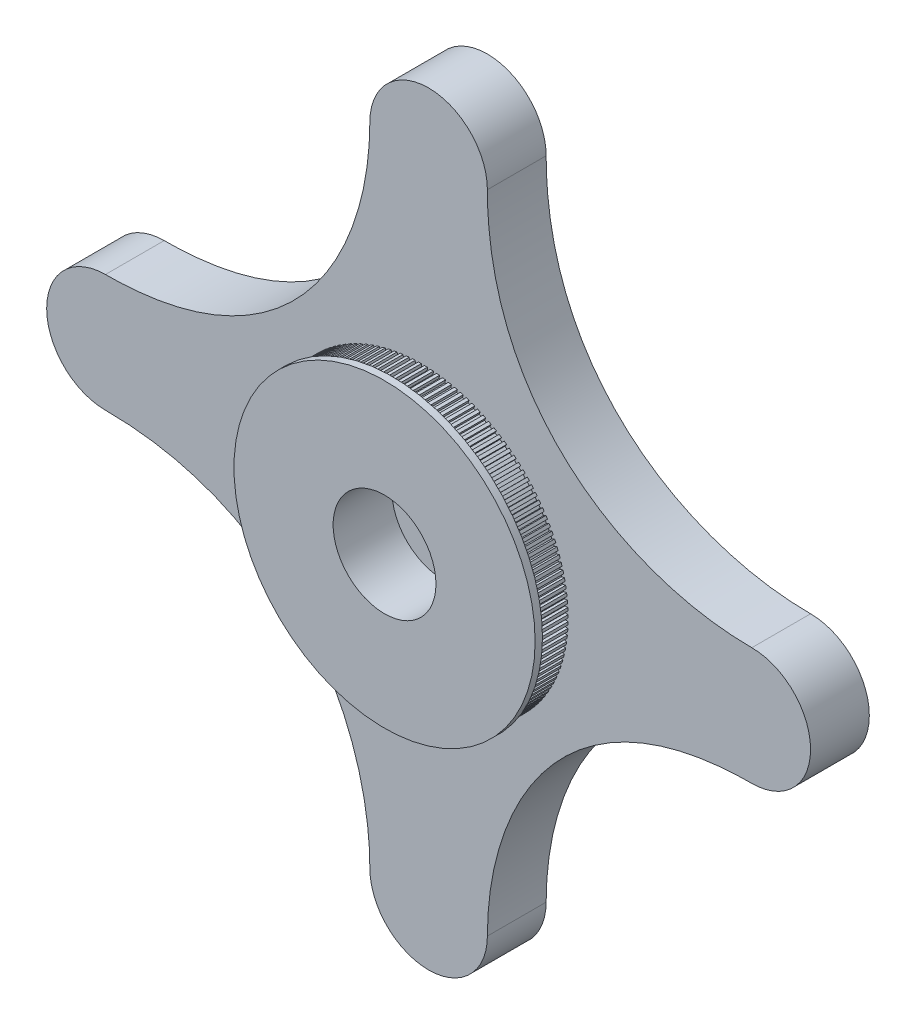
from build123d import *

# Parameters (mm, degrees)
BOSS_EXTRUDE4_DEPTH = 20
SKETCH5_R           = 7.5
BOSS_EXTRUDE5_DEPTH = 2.5
SKETCH6_R           = 45
BOSS_EXTRUDE7_DEPTH = 2.5
SKETCH7_R           = 50
BOSS_EXTRUDE8_DEPTH = 10
SKETCH11_R          = 58.029840761
CUT_EXTRUDE3_DEPTH  = 10
SKETCH9_R           = 51.25
BOSS_EXTRUDE9_DEPTH = 2.5
SKETCH10_R          = 17.5
CUT_EXTRUDE2_DEPTH  = 20


with BuildPart() as part:
    # Sketch1 → Boss-Extrude4 (new body)
    with BuildSketch(Plane.XY):
        with BuildLine():
            ThreePointArc((-20, -110), (0, -130), (20, -110))
            add(Edge.make_bspline(
                [(110, -20), (47.479354006, -20), (20, -67.573593129), (20, -110)],
                knots=[0, 0, 0, 0, 1, 1, 1, 1], degree=3))
            ThreePointArc((110, -20), (130, 0), (110, 20))
            add(Edge.make_bspline(
                [(110, 20), (67.573593129, 20), (20, 47.479354006), (20, 110)],
                knots=[0, 0, 0, 0, 1, 1, 1, 1], degree=3))
            ThreePointArc((20, 110), (0, 130), (-20, 110))
            add(Edge.make_bspline(
                [(-20, 110), (-20, 67.573593129), (-47.479354006, 20), (-110, 20)],
                knots=[0, 0, 0, 0, 1, 1, 1, 1], degree=3))
            ThreePointArc((-110, 20), (-130, 0), (-110, -20))
            add(Edge.make_bspline(
                [(-110, -20), (-47.479354006, -20), (-20, -67.573593129), (-20, -110)],
                knots=[0, 0, 0, 0, 1, 1, 1, 1], degree=3))
        make_face()
    extrude(amount=BOSS_EXTRUDE4_DEPTH)

    # Sketch5 → Boss-Extrude5 (add)
    with BuildSketch(Plane(origin=(0, 0, 0), x_dir=(-1, 0, 0), z_dir=(0, 0, -1))):
        with Locations((0, 110)):
            Circle(SKETCH5_R)
        with Locations((-110, 0)):
            Circle(SKETCH5_R)
        with Locations((0, -110)):
            Circle(SKETCH5_R)
        with Locations((110, 0)):
            Circle(SKETCH5_R)
    extrude(amount=BOSS_EXTRUDE5_DEPTH)

    # Sketch6 → Boss-Extrude7 (add)
    with BuildSketch(Plane.XY.offset(20)):
        Circle(SKETCH6_R)
    extrude(amount=BOSS_EXTRUDE7_DEPTH)

    # Sketch7 → Boss-Extrude8 (add)
    with BuildSketch(Plane.XY.offset(22.5)):
        Circle(SKETCH7_R)
    extrude(amount=BOSS_EXTRUDE8_DEPTH)

    # Sketch11 → Cut-Extrude3 (cut)
    with BuildSketch(Plane.XY.offset(32.5)):
        Circle(SKETCH11_R)
        Polygon((0, -49), (0, -49.994133884), (1, -49.98413171), (1, -48.989794856), (2.024923738, -48.958142161), (2.066006295, -49.951426814), (3.064738714, -49.90010821), (3.023647769, -48.90662076), (4.046387928, -48.832640157), (4.128482854, -49.82337857), (5.124241374, -49.730831213), (5.042129687, -48.739890523), (6.060938932, -48.623708407), (6.183905968, -49.610207919), (7.174989353, -49.476589925), (7.051997211, -48.489889001), (8.065134924, -48.331703867), (8.228763983, -49.31227906), (9.213478983, -49.137818712), (9.049816516, -48.157043317), (10.055551768, -47.957125421), (10.259563293, -48.930101), (11.236227539, -48.715096361), (11.032174361, -47.741922132), (12.02878887, -47.500613031), (12.272834311, -48.464326682), (13.239779188, -48.209145085), (12.995683921, -47.245234674), (13.981474988, -46.96294664), (14.265137397, -47.915751876), (15.220710897, -47.620829293), (14.936990573, -46.667829525), (15.910273991, -46.345044843), (16.233068735, -47.285313811), (17.175638277, -46.951154113), (16.852777628, -46.010693173), (17.811890558, -45.647963315), (18.173266148, -46.574089581), (19.101221366, -46.201263674), (18.739771994, -45.274948322), (19.683075808, -44.872893006), (20.082414841, -45.7832943), (20.99417034, -45.372439151), (20.594749775, -44.461851982), (21.520632854, -44.021158113), (21.957253064, -44.914279029), (22.851251125, -44.466096577), (22.414541771, -43.572793314), (23.321422259, -43.094213809), (23.794577689, -43.968528465), (24.669290932, -43.483784423), (24.196038898, -42.60929126), (25.082367405, -42.093643764), (25.591249677, -42.947658408), (26.445183668, -42.427180952), (25.936197499, -41.572991945), (26.800459748, -41.021157435), (27.344199445, -41.853412997), (28.175895252, -41.298091354), (27.632044541, -40.465665872), (28.472763955, -39.878587146), (29.050432106, -40.687661732), (29.858468792, -40.09844466), (29.280682699, -39.289204887), (30.096422922, -38.66788496), (30.707032591, -39.45239628), (31.490029638, -38.830290447), (30.879295302, -38.045618955), (31.668662655, -37.391119342), (32.311170627, -38.14972707), (33.067790297, -37.495795333), (32.425151146, -36.737032721), (33.18679701, -36.050471623), (33.860105569, -36.781879692), (34.589055191, -36.097239281), (33.915609164, -35.365681883), (34.648232278, -34.648232278), (35.351191089, -35.351191089), (36.051225265, -34.637011703), (35.348122933, -33.93390937), (36.050471623, -33.18679701), (36.781879692, -33.860105569), (37.451802425, -33.11760737), (36.720245026, -32.444161343), (37.391119342, -31.668662655), (38.14972707, -32.311170627), (38.788393808, -31.541622161), (38.029631197, -30.89898301), (38.66788496, -30.096422922), (39.45239628, -30.707032591), (40.058715872, -29.91174862), (39.27404438, -29.301014283), (39.878587146, -28.472763955), (40.687661732, -29.050432106), (41.260598291, -28.230771357), (40.451358518, -27.652985265), (41.021157435, -26.800459748), (41.853412997, -27.344199445), (42.391987671, -26.501562296), (41.559562188, -25.957711585), (42.093643764, -25.082367405), (42.947658408, -25.591249677), (43.45095105, -24.72707576), (42.596762044, -24.21808959), (43.094213809, -23.321422259), (43.968528465, -23.794577689), (44.435679209, -22.910343429), (43.561186046, -22.437091396), (44.021158113, -21.520632854), (44.914279029, -21.957253064), (45.344489755, -21.054469162), (44.451186492, -20.617759807), (44.872893006, -19.683075808), (45.7832943, -20.082414841), (46.17583, -19.162623686), (45.265242832, -18.763203122), (45.647963315, -17.811890558), (46.574089581, -18.173266148), (46.928279615, -17.23803919), (46.001964264, -16.876589818), (46.345044843, -15.910273991), (47.285313811, -16.233068735), (47.600553052, -15.284003793), (46.660092111, -14.961143144), (46.96294664, -13.981474988), (47.915751876, -14.265137397), (48.191501742, -13.303855932), (47.238501974, -13.020135608), (47.500613031, -12.02878887), (48.464326682, -12.272834311), (48.700116059, -11.300978656), (47.736205649, -11.056883389), (47.957125421, -10.055551768), (48.930101, -10.259563293), (49.125527046, -9.278793848), (48.152352817, -9.07474067), (48.331703867, -8.065134924), (49.31227906, -8.228763983), (49.467007893, -7.240756376), (48.486232498, -7.077093909), (48.623708407, -6.060938932), (49.610207919, -6.183905968), (49.723975187, -5.190348193), (48.737274264, -5.067356051), (48.832640157, -4.046387928), (49.82337857, -4.128482854), (49.895989904, -3.131072388), (48.905049214, -3.048960701), (48.958142161, -2.024923738), (49.951426814, -2.066006295), (49.982758159, -1.066447197), (48.989270709, -1.025356252), (49, 0), (49.994133884, 0), (49.98413171, 1), (48.989794856, 1), (48.958142161, 2.024923738), (49.951426814, 2.066006295), (49.90010821, 3.064738714), (48.90662076, 3.023647769), (48.832640157, 4.046387928), (49.82337857, 4.128482854), (49.730831213, 5.124241374), (48.739890523, 5.042129687), (48.623708407, 6.060938932), (49.610207919, 6.183905968), (49.476589925, 7.174989353), (48.489889001, 7.051997211), (48.331703867, 8.065134924), (49.31227906, 8.228763983), (49.137818712, 9.213478983), (48.157043317, 9.049816516), (47.957125421, 10.055551768), (48.930101, 10.259563293), (48.715096361, 11.236227539), (47.741922132, 11.032174361), (47.500613031, 12.02878887), (48.464326682, 12.272834311), (48.209145085, 13.239779188), (47.245234674, 12.995683921), (46.96294664, 13.981474988), (47.915751876, 14.265137397), (47.620829293, 15.220710897), (46.667829525, 14.936990573), (46.345044843, 15.910273991), (47.285313811, 16.233068735), (46.951154113, 17.175638277), (46.010693173, 16.852777628), (45.647963315, 17.811890558), (46.574089581, 18.173266148), (46.201263674, 19.101221366), (45.274948322, 18.739771994), (44.872893006, 19.683075808), (45.7832943, 20.082414841), (45.372439151, 20.99417034), (44.461851982, 20.594749775), (44.021158113, 21.520632854), (44.914279029, 21.957253064), (44.466096577, 22.851251125), (43.572793314, 22.414541771), (43.094213809, 23.321422259), (43.968528465, 23.794577689), (43.483784423, 24.669290932), (42.60929126, 24.196038898), (42.093643764, 25.082367405), (42.947658408, 25.591249677), (42.427180952, 26.445183668), (41.572991945, 25.936197499), (41.021157435, 26.800459748), (41.853412997, 27.344199445), (41.298091354, 28.175895252), (40.465665872, 27.632044541), (39.878587146, 28.472763955), (40.687661732, 29.050432106), (40.09844466, 29.858468792), (39.289204887, 29.280682699), (38.66788496, 30.096422922), (39.45239628, 30.707032591), (38.830290447, 31.490029638), (38.045618955, 30.879295302), (37.391119342, 31.668662655), (38.14972707, 32.311170627), (37.495795333, 33.067790297), (36.737032721, 32.425151146), (36.050471623, 33.18679701), (36.781879692, 33.860105569), (36.097239281, 34.589055191), (35.365681883, 33.915609164), (34.648232278, 34.648232278), (35.351191089, 35.351191089), (34.637011703, 36.051225265), (33.93390937, 35.348122933), (33.18679701, 36.050471623), (33.860105569, 36.781879692), (33.11760737, 37.451802425), (32.444161343, 36.720245026), (31.668662655, 37.391119342), (32.311170627, 38.14972707), (31.541622161, 38.788393808), (30.89898301, 38.029631197), (30.096422922, 38.66788496), (30.707032591, 39.45239628), (29.91174862, 40.058715872), (29.301014283, 39.27404438), (28.472763955, 39.878587146), (29.050432106, 40.687661732), (28.230771357, 41.260598291), (27.652985265, 40.451358518), (26.800459748, 41.021157435), (27.344199445, 41.853412997), (26.501562296, 42.391987671), (25.957711585, 41.559562188), (25.082367405, 42.093643764), (25.591249677, 42.947658408), (24.72707576, 43.45095105), (24.21808959, 42.596762044), (23.321422259, 43.094213809), (23.794577689, 43.968528465), (22.910343429, 44.435679209), (22.437091396, 43.561186046), (21.520632854, 44.021158113), (21.957253064, 44.914279029), (21.054469162, 45.344489755), (20.617759807, 44.451186492), (19.683075808, 44.872893006), (20.082414841, 45.7832943), (19.162623686, 46.17583), (18.763203122, 45.265242832), (17.811890558, 45.647963315), (18.173266148, 46.574089581), (17.23803919, 46.928279615), (16.876589818, 46.001964264), (15.910273991, 46.345044843), (16.233068735, 47.285313811), (15.284003793, 47.600553052), (14.961143144, 46.660092111), (13.981474988, 46.96294664), (14.265137397, 47.915751876), (13.303855932, 48.191501742), (13.020135608, 47.238501974), (12.02878887, 47.500613031), (12.272834311, 48.464326682), (11.300978656, 48.700116059), (11.056883389, 47.736205649), (10.055551768, 47.957125421), (10.259563293, 48.930101), (9.278793848, 49.125527046), (9.07474067, 48.152352817), (8.065134924, 48.331703867), (8.228763983, 49.31227906), (7.240756376, 49.467007893), (7.077093909, 48.486232498), (6.060938932, 48.623708407), (6.183905968, 49.610207919), (5.190348193, 49.723975187), (5.067356051, 48.737274264), (4.046387928, 48.832640157), (4.128482854, 49.82337857), (3.131072388, 49.895989904), (3.048960701, 48.905049214), (2.024923738, 48.958142161), (2.066006295, 49.951426814), (1.066447197, 49.982758159), (1.025356252, 48.989270709), (0, 49), (0, 49.994133884), (-1, 49.98413171), (-1, 48.989794856), (-2.024923738, 48.958142161), (-2.066006295, 49.951426814), (-3.064738714, 49.90010821), (-3.023647769, 48.90662076), (-4.046387928, 48.832640157), (-4.128482854, 49.82337857), (-5.124241374, 49.730831213), (-5.042129687, 48.739890523), (-6.060938932, 48.623708407), (-6.183905968, 49.610207919), (-7.174989353, 49.476589925), (-7.051997211, 48.489889001), (-8.065134924, 48.331703867), (-8.228763983, 49.31227906), (-9.213478983, 49.137818712), (-9.049816516, 48.157043317), (-10.055551768, 47.957125421), (-10.259563293, 48.930101), (-11.236227539, 48.715096361), (-11.032174361, 47.741922132), (-12.02878887, 47.500613031), (-12.272834311, 48.464326682), (-13.239779188, 48.209145085), (-12.995683921, 47.245234674), (-13.981474988, 46.96294664), (-14.265137397, 47.915751876), (-15.220710897, 47.620829293), (-14.936990573, 46.667829525), (-15.910273991, 46.345044843), (-16.233068735, 47.285313811), (-17.175638277, 46.951154113), (-16.852777628, 46.010693173), (-17.811890558, 45.647963315), (-18.173266148, 46.574089581), (-19.101221366, 46.201263674), (-18.739771994, 45.274948322), (-19.683075808, 44.872893006), (-20.082414841, 45.7832943), (-20.99417034, 45.372439151), (-20.594749775, 44.461851982), (-21.520632854, 44.021158113), (-21.957253064, 44.914279029), (-22.851251125, 44.466096577), (-22.414541771, 43.572793314), (-23.321422259, 43.094213809), (-23.794577689, 43.968528465), (-24.669290932, 43.483784423), (-24.196038898, 42.60929126), (-25.082367405, 42.093643764), (-25.591249677, 42.947658408), (-26.445183668, 42.427180952), (-25.936197499, 41.572991945), (-26.800459748, 41.021157435), (-27.344199445, 41.853412997), (-28.175895252, 41.298091354), (-27.632044541, 40.465665872), (-28.472763955, 39.878587146), (-29.050432106, 40.687661732), (-29.858468792, 40.09844466), (-29.280682699, 39.289204887), (-30.096422922, 38.66788496), (-30.707032591, 39.45239628), (-31.490029638, 38.830290447), (-30.879295302, 38.045618955), (-31.668662655, 37.391119342), (-32.311170627, 38.14972707), (-33.067790297, 37.495795333), (-32.425151146, 36.737032721), (-33.18679701, 36.050471623), (-33.860105569, 36.781879692), (-34.589055191, 36.097239281), (-33.915609164, 35.365681883), (-34.648232278, 34.648232278), (-35.351191089, 35.351191089), (-36.051225265, 34.637011703), (-35.348122933, 33.93390937), (-36.050471623, 33.18679701), (-36.781879692, 33.860105569), (-37.451802425, 33.11760737), (-36.720245026, 32.444161343), (-37.391119342, 31.668662655), (-38.14972707, 32.311170627), (-38.788393808, 31.541622161), (-38.029631197, 30.89898301), (-38.66788496, 30.096422922), (-39.45239628, 30.707032591), (-40.058715872, 29.91174862), (-39.27404438, 29.301014283), (-39.878587146, 28.472763955), (-40.687661732, 29.050432106), (-41.260598291, 28.230771357), (-40.451358518, 27.652985265), (-41.021157435, 26.800459748), (-41.853412997, 27.344199445), (-42.391987671, 26.501562296), (-41.559562188, 25.957711585), (-42.093643764, 25.082367405), (-42.947658408, 25.591249677), (-43.45095105, 24.72707576), (-42.596762044, 24.21808959), (-43.094213809, 23.321422259), (-43.968528465, 23.794577689), (-44.435679209, 22.910343429), (-43.561186046, 22.437091396), (-44.021158113, 21.520632854), (-44.914279029, 21.957253064), (-45.344489755, 21.054469162), (-44.451186492, 20.617759807), (-44.872893006, 19.683075808), (-45.7832943, 20.082414841), (-46.17583, 19.162623686), (-45.265242832, 18.763203122), (-45.647963315, 17.811890558), (-46.574089581, 18.173266148), (-46.928279615, 17.23803919), (-46.001964264, 16.876589818), (-46.345044843, 15.910273991), (-47.285313811, 16.233068735), (-47.600553052, 15.284003793), (-46.660092111, 14.961143144), (-46.96294664, 13.981474988), (-47.915751876, 14.265137397), (-48.191501742, 13.303855932), (-47.238501974, 13.020135608), (-47.500613031, 12.02878887), (-48.464326682, 12.272834311), (-48.700116059, 11.300978656), (-47.736205649, 11.056883389), (-47.957125421, 10.055551768), (-48.930101, 10.259563293), (-49.125527046, 9.278793848), (-48.152352817, 9.07474067), (-48.331703867, 8.065134924), (-49.31227906, 8.228763983), (-49.467007893, 7.240756376), (-48.486232498, 7.077093909), (-48.623708407, 6.060938932), (-49.610207919, 6.183905968), (-49.723975187, 5.190348193), (-48.737274264, 5.067356051), (-48.832640157, 4.046387928), (-49.82337857, 4.128482854), (-49.895989904, 3.131072388), (-48.905049214, 3.048960701), (-48.958142161, 2.024923738), (-49.951426814, 2.066006295), (-49.982758159, 1.066447197), (-48.989270709, 1.025356252), (-49, 0), (-49.994133884, 0), (-49.98413171, -1), (-48.989794856, -1), (-48.958142161, -2.024923738), (-49.951426814, -2.066006295), (-49.90010821, -3.064738714), (-48.90662076, -3.023647769), (-48.832640157, -4.046387928), (-49.82337857, -4.128482854), (-49.730831213, -5.124241374), (-48.739890523, -5.042129687), (-48.623708407, -6.060938932), (-49.610207919, -6.183905968), (-49.476589925, -7.174989353), (-48.489889001, -7.051997211), (-48.331703867, -8.065134924), (-49.31227906, -8.228763983), (-49.137818712, -9.213478983), (-48.157043317, -9.049816516), (-47.957125421, -10.055551768), (-48.930101, -10.259563293), (-48.715096361, -11.236227539), (-47.741922132, -11.032174361), (-47.500613031, -12.02878887), (-48.464326682, -12.272834311), (-48.209145085, -13.239779188), (-47.245234674, -12.995683921), (-46.96294664, -13.981474988), (-47.915751876, -14.265137397), (-47.620829293, -15.220710897), (-46.667829525, -14.936990573), (-46.345044843, -15.910273991), (-47.285313811, -16.233068735), (-46.951154113, -17.175638277), (-46.010693173, -16.852777628), (-45.647963315, -17.811890558), (-46.574089581, -18.173266148), (-46.201263674, -19.101221366), (-45.274948322, -18.739771994), (-44.872893006, -19.683075808), (-45.7832943, -20.082414841), (-45.372439151, -20.99417034), (-44.461851982, -20.594749775), (-44.021158113, -21.520632854), (-44.914279029, -21.957253064), (-44.466096577, -22.851251125), (-43.572793314, -22.414541771), (-43.094213809, -23.321422259), (-43.968528465, -23.794577689), (-43.483784423, -24.669290932), (-42.60929126, -24.196038898), (-42.093643764, -25.082367405), (-42.947658408, -25.591249677), (-42.427180952, -26.445183668), (-41.572991945, -25.936197499), (-41.021157435, -26.800459748), (-41.853412997, -27.344199445), (-41.298091354, -28.175895252), (-40.465665872, -27.632044541), (-39.878587146, -28.472763955), (-40.687661732, -29.050432106), (-40.09844466, -29.858468792), (-39.289204887, -29.280682699), (-38.66788496, -30.096422922), (-39.45239628, -30.707032591), (-38.830290447, -31.490029638), (-38.045618955, -30.879295302), (-37.391119342, -31.668662655), (-38.14972707, -32.311170627), (-37.495795333, -33.067790297), (-36.737032721, -32.425151146), (-36.050471623, -33.18679701), (-36.781879692, -33.860105569), (-36.097239281, -34.589055191), (-35.365681883, -33.915609164), (-34.648232278, -34.648232278), (-35.351191089, -35.351191089), (-34.637011703, -36.051225265), (-33.93390937, -35.348122933), (-33.18679701, -36.050471623), (-33.860105569, -36.781879692), (-33.11760737, -37.451802425), (-32.444161343, -36.720245026), (-31.668662655, -37.391119342), (-32.311170627, -38.14972707), (-31.541622161, -38.788393808), (-30.89898301, -38.029631197), (-30.096422922, -38.66788496), (-30.707032591, -39.45239628), (-29.91174862, -40.058715872), (-29.301014283, -39.27404438), (-28.472763955, -39.878587146), (-29.050432106, -40.687661732), (-28.230771357, -41.260598291), (-27.652985265, -40.451358518), (-26.800459748, -41.021157435), (-27.344199445, -41.853412997), (-26.501562296, -42.391987671), (-25.957711585, -41.559562188), (-25.082367405, -42.093643764), (-25.591249677, -42.947658408), (-24.72707576, -43.45095105), (-24.21808959, -42.596762044), (-23.321422259, -43.094213809), (-23.794577689, -43.968528465), (-22.910343429, -44.435679209), (-22.437091396, -43.561186046), (-21.520632854, -44.021158113), (-21.957253064, -44.914279029), (-21.054469162, -45.344489755), (-20.617759807, -44.451186492), (-19.683075808, -44.872893006), (-20.082414841, -45.7832943), (-19.162623686, -46.17583), (-18.763203122, -45.265242832), (-17.811890558, -45.647963315), (-18.173266148, -46.574089581), (-17.23803919, -46.928279615), (-16.876589818, -46.001964264), (-15.910273991, -46.345044843), (-16.233068735, -47.285313811), (-15.284003793, -47.600553052), (-14.961143144, -46.660092111), (-13.981474988, -46.96294664), (-14.265137397, -47.915751876), (-13.303855932, -48.191501742), (-13.020135608, -47.238501974), (-12.02878887, -47.500613031), (-12.272834311, -48.464326682), (-11.300978656, -48.700116059), (-11.056883389, -47.736205649), (-10.055551768, -47.957125421), (-10.259563293, -48.930101), (-9.278793848, -49.125527046), (-9.07474067, -48.152352817), (-8.065134924, -48.331703867), (-8.228763983, -49.31227906), (-7.240756376, -49.467007893), (-7.077093909, -48.486232498), (-6.060938932, -48.623708407), (-6.183905968, -49.610207919), (-5.190348193, -49.723975187), (-5.067356051, -48.737274264), (-4.046387928, -48.832640157), (-4.128482854, -49.82337857), (-3.131072388, -49.895989904), (-3.048960701, -48.905049214), (-2.024923738, -48.958142161), (-2.066006295, -49.951426814), (-1.066447197, -49.982758159), (-1.025356252, -48.989270709), align=None, mode=Mode.SUBTRACT)
    extrude(amount=-CUT_EXTRUDE3_DEPTH, mode=Mode.SUBTRACT)

    # Sketch9 → Boss-Extrude9 (add)
    with BuildSketch(Plane.XY.offset(32.5)):
        Circle(SKETCH9_R)
    extrude(amount=BOSS_EXTRUDE9_DEPTH)

    # Sketch10 → Cut-Extrude2 (cut)
    with BuildSketch(Plane.XY.offset(35)):
        Circle(SKETCH10_R)
    extrude(amount=-CUT_EXTRUDE2_DEPTH, mode=Mode.SUBTRACT)


solid = part.part
